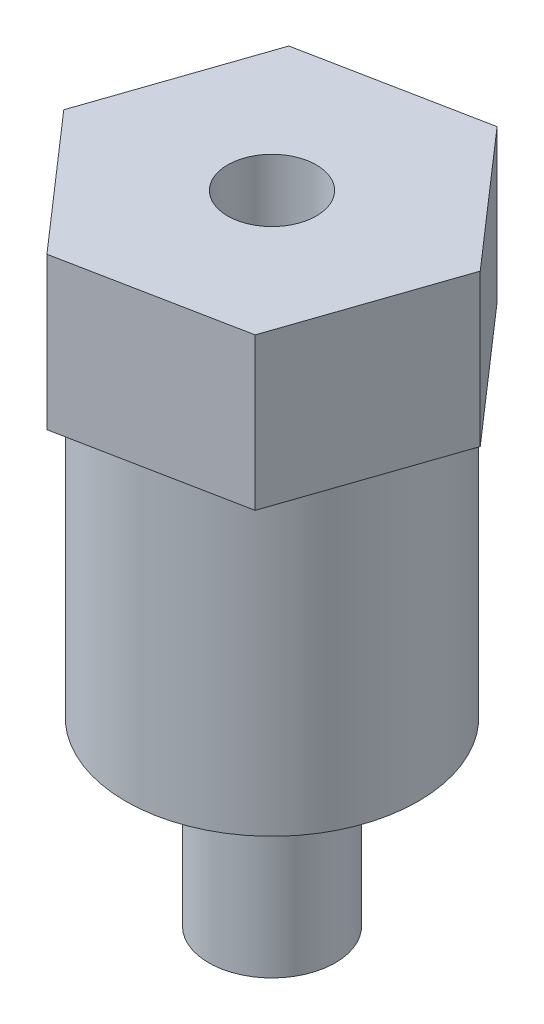
from build123d import *

# Parameters (mm, degrees)
BOSS_EXTRUDE1_DEPTH = 6
SKETCH2_R           = 5.775
BOSS_EXTRUDE2_DEPTH = 18
SKETCH3_R           = 2.5
BOSS_EXTRUDE3_DEPTH = 7.16
SKETCH4_R           = 1.75
CUT_EXTRUDE1_DEPTH  = 10


with BuildPart() as part:
    # Sketch1 → Boss-Extrude1 (new body)
    with BuildSketch(Plane(origin=(0, 0, 0), x_dir=(1, 0, 0), z_dir=(0, 1, 0))):
        Polygon((4.605908032, -5.271205859), (6.867952198, 1.353230434), (2.262044166, 6.624436292), (-4.605908032, 5.271205859), (-6.867952198, -1.353230434), (-2.262044166, -6.624436292), align=None)
    extrude(amount=BOSS_EXTRUDE1_DEPTH)

    # Sketch2 → Boss-Extrude2 (add)
    with BuildSketch(Plane(origin=(0, 6, 0), x_dir=(1, 0, 0), z_dir=(0, 1, 0))):
        Circle(SKETCH2_R)
    extrude(amount=-BOSS_EXTRUDE2_DEPTH)

    # Sketch3 → Boss-Extrude3 (add)
    with BuildSketch(Plane.XZ.offset(12)):
        Circle(SKETCH3_R)
    extrude(amount=BOSS_EXTRUDE3_DEPTH)

    # Sketch4 → Cut-Extrude1 (cut)
    with BuildSketch(Plane(origin=(0, 6, 0), x_dir=(1, 0, 0), z_dir=(0, 1, 0))):
        Circle(SKETCH4_R)
    extrude(amount=-CUT_EXTRUDE1_DEPTH, mode=Mode.SUBTRACT)


solid = part.part
